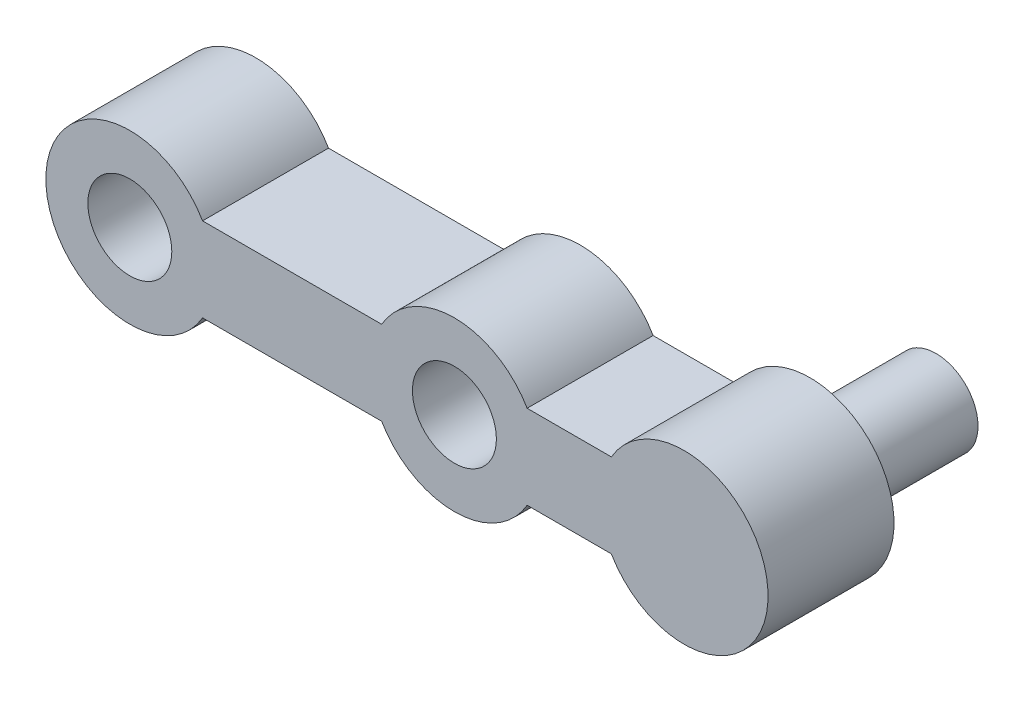
from build123d import *

# Parameters (mm, degrees)
BOSS_EXTRUDE1_DEPTH = 3
SKETCH3_R           = 1
CUT_EXTRUDE1_DEPTH  = 3
SKETCH4_R           = 1
BOSS_EXTRUDE2_DEPTH = 3


with BuildPart() as part:
    # Sketch2 → Boss-Extrude1 (new body)
    with BuildSketch(Plane.XY):
        with BuildLine():
            Line((-17.378860002, -4.822654682), (-13.112961617, -4.822654682))
            ThreePointArc((-13.112961617, -4.822654682), (-11.380910809, -3.822654682), (-9.648860002, -4.822654682))
            Line((-9.648860002, -4.822654682), (-7.642961617, -4.822654682))
            ThreePointArc((-7.642961617, -4.822654682), (-3.910910809, -5.822654682), (-7.642961617, -6.822654682))
            Line((-7.642961617, -6.822654682), (-9.648860002, -6.822654682))
            ThreePointArc((-9.648860002, -6.822654682), (-11.380910809, -7.822654682), (-13.112961617, -6.822654682))
            Line((-13.112961617, -6.822654682), (-17.378860002, -6.822654682))
            ThreePointArc((-17.378860002, -6.822654682), (-21.110910809, -5.822654682), (-17.378860002, -4.822654682))
        make_face()
    extrude(amount=BOSS_EXTRUDE1_DEPTH)

    # Sketch3 → Cut-Extrude1 (cut)
    with BuildSketch(Plane.XY.offset(3)):
        with Locations((-11.380910809, -5.822654682)):
            Circle(SKETCH3_R)
        with Locations((-19.110910809, -5.822654682)):
            Circle(SKETCH3_R)
    extrude(amount=-CUT_EXTRUDE1_DEPTH, mode=Mode.SUBTRACT)

    # Sketch4 → Boss-Extrude2 (add)
    with BuildSketch(Plane(origin=(0, 0, 0), x_dir=(-1, 0, 0), z_dir=(0, 0, -1))):
        with Locations((5.910910809, -5.822654682)):
            Circle(SKETCH4_R)
    extrude(amount=BOSS_EXTRUDE2_DEPTH)


solid = part.part
